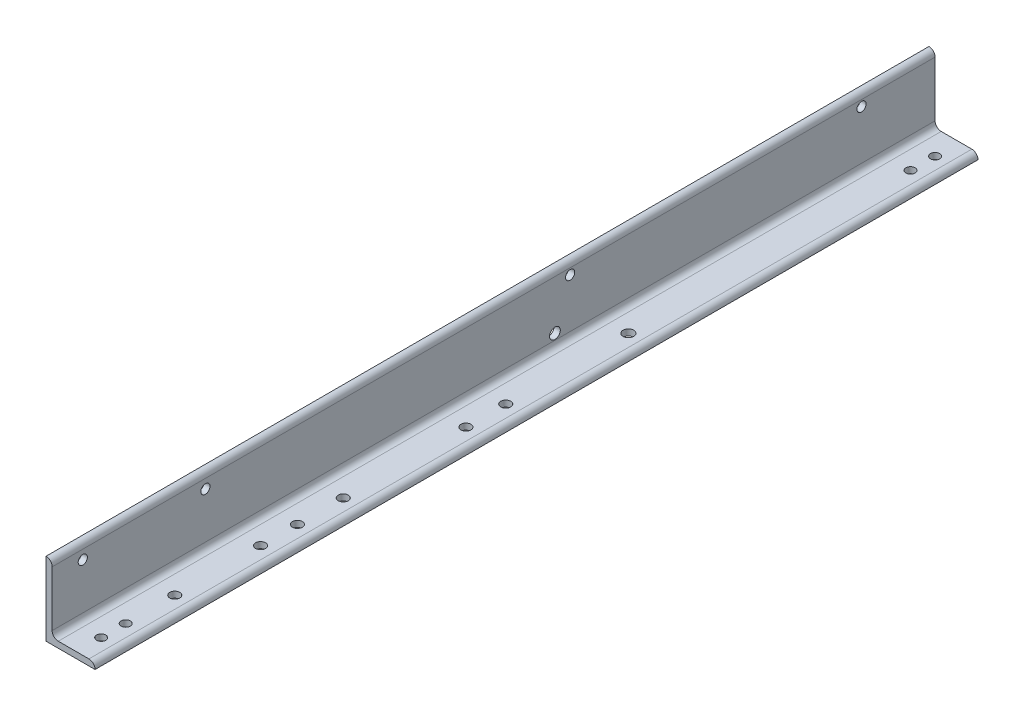
from build123d import *

# Parameters (mm, degrees)
BOSS_EXTRUDE1_DEPTH = 914.4
CUT_EXTRUDE2_REACH  = 14.7
SKETCH3_R           = 9.525
SKETCH3_R_2         = 10.31875
SKETCH3_R_3         = 11.1125
CUT_EXTRUDE3_REACH  = 14.7
SKETCH4_R           = 9.525
SKETCH5_R           = 11.1125
CUT_EXTRUDE4_DEPTH  = 102.6


with BuildPart() as part:
    # Sketch1 → Boss-Extrude1 (new body, symmetric)
    with BuildSketch(Plane.XY):
        with BuildLine():
            Line((0, 0), (0, 152.4))
            Line((0, 152.4), (0.00508, 152.4))
            ThreePointArc((0.00508, 152.4), (8.981744019, 148.681744019), (12.7, 139.70508))
            Line((12.7, 139.70508), (12.7, 25.4))
            ThreePointArc((12.7, 25.4), (16.419743879, 16.419743879), (25.4, 12.7))
            Line((25.4, 12.7), (88.90508, 12.7))
            ThreePointArc((88.90508, 12.7), (97.881744019, 8.981744019), (101.6, 0.00508))
            Line((101.6, 0.00508), (101.6, 0))
            Line((101.6, 0), (0, 0))
        make_face()
    extrude(amount=BOSS_EXTRUDE1_DEPTH, both=True)

    # Sketch3 → Cut-Extrude2 (cut, up to next)
    with BuildSketch(Plane(origin=(0, 12.7, 0), x_dir=(1, 0, 0), z_dir=(0, 1, 0)), mode=Mode.PRIVATE) as cut_extrude2_sk1:
        with Locations((63.5, -863.6)):
            Circle(SKETCH3_R)
    cut_extrude2_tool1 = extrude(cut_extrude2_sk1.sketch, amount=-CUT_EXTRUDE2_REACH, mode=Mode.PRIVATE) & part.part
    add(cut_extrude2_tool1.solids().sort_by_distance((63.5, 12.7, 863.6))[0], mode=Mode.SUBTRACT)
    # Sketch3 → Cut-Extrude2 (cut, up to next)
    with BuildSketch(Plane(origin=(0, 12.7, 0), x_dir=(1, 0, 0), z_dir=(0, 1, 0)), mode=Mode.PRIVATE) as cut_extrude2_sk2:
        with Locations((63.5, 863.6)):
            Circle(SKETCH3_R)
    cut_extrude2_tool2 = extrude(cut_extrude2_sk2.sketch, amount=-CUT_EXTRUDE2_REACH, mode=Mode.PRIVATE) & part.part
    add(cut_extrude2_tool2.solids().sort_by_distance((63.5, 12.7, -863.6))[0], mode=Mode.SUBTRACT)
    # Sketch3 → Cut-Extrude2 (cut, up to next)
    with BuildSketch(Plane(origin=(0, 12.7, 0), x_dir=(1, 0, 0), z_dir=(0, 1, 0)), mode=Mode.PRIVATE) as cut_extrude2_sk3:
        with Locations((63.5, -711.2)):
            Circle(SKETCH3_R_2)
    cut_extrude2_tool3 = extrude(cut_extrude2_sk3.sketch, amount=-CUT_EXTRUDE2_REACH, mode=Mode.PRIVATE) & part.part
    add(cut_extrude2_tool3.solids().sort_by_distance((63.5, 12.7, 711.2))[0], mode=Mode.SUBTRACT)
    # Sketch3 → Cut-Extrude2 (cut, up to next)
    with BuildSketch(Plane(origin=(0, 12.7, 0), x_dir=(1, 0, 0), z_dir=(0, 1, 0)), mode=Mode.PRIVATE) as cut_extrude2_sk4:
        with Locations((63.5, -457.2)):
            Circle(SKETCH3_R_2)
    cut_extrude2_tool4 = extrude(cut_extrude2_sk4.sketch, amount=-CUT_EXTRUDE2_REACH, mode=Mode.PRIVATE) & part.part
    add(cut_extrude2_tool4.solids().sort_by_distance((63.5, 12.7, 457.2))[0], mode=Mode.SUBTRACT)
    # Sketch3 → Cut-Extrude2 (cut, up to next)
    with BuildSketch(Plane(origin=(0, 12.7, 0), x_dir=(1, 0, 0), z_dir=(0, 1, 0)), mode=Mode.PRIVATE) as cut_extrude2_sk5:
        with Locations((63.5, -108.204)):
            Circle(SKETCH3_R_2)
    cut_extrude2_tool5 = extrude(cut_extrude2_sk5.sketch, amount=-CUT_EXTRUDE2_REACH, mode=Mode.PRIVATE) & part.part
    add(cut_extrude2_tool5.solids().sort_by_distance((63.5, 12.7, 108.204))[0], mode=Mode.SUBTRACT)
    # Sketch3 → Cut-Extrude2 (cut, up to next)
    with BuildSketch(Plane(origin=(0, 12.7, 0), x_dir=(1, 0, 0), z_dir=(0, 1, 0)), mode=Mode.PRIVATE) as cut_extrude2_sk6:
        with Locations((63.5, -533.4)):
            Circle(SKETCH3_R_2)
    cut_extrude2_tool6 = extrude(cut_extrude2_sk6.sketch, amount=-CUT_EXTRUDE2_REACH, mode=Mode.PRIVATE) & part.part
    add(cut_extrude2_tool6.solids().sort_by_distance((63.5, 12.7, 533.4))[0], mode=Mode.SUBTRACT)
    # Sketch3 → Cut-Extrude2 (cut, up to next)
    with BuildSketch(Plane(origin=(0, 12.7, 0), x_dir=(1, 0, 0), z_dir=(0, 1, 0)), mode=Mode.PRIVATE) as cut_extrude2_sk7:
        with Locations((63.5, -25.654)):
            Circle(SKETCH3_R_2)
    cut_extrude2_tool7 = extrude(cut_extrude2_sk7.sketch, amount=-CUT_EXTRUDE2_REACH, mode=Mode.PRIVATE) & part.part
    add(cut_extrude2_tool7.solids().sort_by_distance((63.5, 12.7, 25.654))[0], mode=Mode.SUBTRACT)
    # Sketch3 → Cut-Extrude2 (cut, up to next)
    with BuildSketch(Plane(origin=(0, 12.7, 0), x_dir=(1, 0, 0), z_dir=(0, 1, 0)), mode=Mode.PRIVATE) as cut_extrude2_sk8:
        with Locations((63.5, 228.346)):
            Circle(SKETCH3_R_3)
    cut_extrude2_tool8 = extrude(cut_extrude2_sk8.sketch, amount=-CUT_EXTRUDE2_REACH, mode=Mode.PRIVATE) & part.part
    add(cut_extrude2_tool8.solids().sort_by_distance((63.5, 12.7, -228.346))[0], mode=Mode.SUBTRACT)
    # Sketch3 → Cut-Extrude2 (cut, up to next)
    with BuildSketch(Plane(origin=(0, 12.7, 0), x_dir=(1, 0, 0), z_dir=(0, 1, 0)), mode=Mode.PRIVATE) as cut_extrude2_sk9:
        with Locations((63.5, -362.204)):
            Circle(SKETCH3_R_2)
    cut_extrude2_tool9 = extrude(cut_extrude2_sk9.sketch, amount=-CUT_EXTRUDE2_REACH, mode=Mode.PRIVATE) & part.part
    add(cut_extrude2_tool9.solids().sort_by_distance((63.5, 12.7, 362.204))[0], mode=Mode.SUBTRACT)
    # Sketch3 → Cut-Extrude2 (cut, up to next)
    with BuildSketch(Plane(origin=(0, 12.7, 0), x_dir=(1, 0, 0), z_dir=(0, 1, 0)), mode=Mode.PRIVATE) as cut_extrude2_sk10:
        with Locations((63.5, 812.8)):
            Circle(SKETCH3_R)
    cut_extrude2_tool10 = extrude(cut_extrude2_sk10.sketch, amount=-CUT_EXTRUDE2_REACH, mode=Mode.PRIVATE) & part.part
    add(cut_extrude2_tool10.solids().sort_by_distance((63.5, 12.7, -812.8))[0], mode=Mode.SUBTRACT)
    # Sketch3 → Cut-Extrude2 (cut, up to next)
    with BuildSketch(Plane(origin=(0, 12.7, 0), x_dir=(1, 0, 0), z_dir=(0, 1, 0)), mode=Mode.PRIVATE) as cut_extrude2_sk11:
        with Locations((63.5, -812.8)):
            Circle(SKETCH3_R)
    cut_extrude2_tool11 = extrude(cut_extrude2_sk11.sketch, amount=-CUT_EXTRUDE2_REACH, mode=Mode.PRIVATE) & part.part
    add(cut_extrude2_tool11.solids().sort_by_distance((63.5, 12.7, 812.8))[0], mode=Mode.SUBTRACT)

    # Sketch4 → Cut-Extrude3 (cut, up to next)
    with BuildSketch(Plane(origin=(12.7, 0, 0), x_dir=(0, 0, -1), z_dir=(1, 0, 0)), mode=Mode.PRIVATE) as cut_extrude3_sk1:
        with Locations((-850.9, 120.65)):
            Circle(SKETCH4_R)
    cut_extrude3_tool1 = extrude(cut_extrude3_sk1.sketch, amount=-CUT_EXTRUDE3_REACH, mode=Mode.PRIVATE) & part.part
    add(cut_extrude3_tool1.solids().sort_by_distance((12.7, 120.65, 850.9))[0], mode=Mode.SUBTRACT)
    # Sketch4 → Cut-Extrude3 (cut, up to next)
    with BuildSketch(Plane(origin=(12.7, 0, 0), x_dir=(0, 0, -1), z_dir=(1, 0, 0)), mode=Mode.PRIVATE) as cut_extrude3_sk2:
        with Locations((-596.9, 120.65)):
            Circle(SKETCH4_R)
    cut_extrude3_tool2 = extrude(cut_extrude3_sk2.sketch, amount=-CUT_EXTRUDE3_REACH, mode=Mode.PRIVATE) & part.part
    add(cut_extrude3_tool2.solids().sort_by_distance((12.7, 120.65, 596.9))[0], mode=Mode.SUBTRACT)
    # Sketch4 → Cut-Extrude3 (cut, up to next)
    with BuildSketch(Plane(origin=(12.7, 0, 0), x_dir=(0, 0, -1), z_dir=(1, 0, 0)), mode=Mode.PRIVATE) as cut_extrude3_sk3:
        with Locations((158.496, 127)):
            Circle(SKETCH4_R)
    cut_extrude3_tool3 = extrude(cut_extrude3_sk3.sketch, amount=-CUT_EXTRUDE3_REACH, mode=Mode.PRIVATE) & part.part
    add(cut_extrude3_tool3.solids().sort_by_distance((12.7, 127, -158.496))[0], mode=Mode.SUBTRACT)
    # Sketch4 → Cut-Extrude3 (cut, up to next)
    with BuildSketch(Plane(origin=(12.7, 0, 0), x_dir=(0, 0, -1), z_dir=(1, 0, 0)), mode=Mode.PRIVATE) as cut_extrude3_sk4:
        with Locations((762, 127)):
            Circle(SKETCH4_R)
    cut_extrude3_tool4 = extrude(cut_extrude3_sk4.sketch, amount=-CUT_EXTRUDE3_REACH, mode=Mode.PRIVATE) & part.part
    add(cut_extrude3_tool4.solids().sort_by_distance((12.7, 127, -762))[0], mode=Mode.SUBTRACT)

    # Sketch5 → Cut-Extrude4 (cut, through all)
    with BuildSketch(Plane.ZY):
        with Locations((-127, 38.1)):
            Circle(SKETCH5_R)
    extrude(amount=-CUT_EXTRUDE4_DEPTH, mode=Mode.SUBTRACT)


solid = part.part
